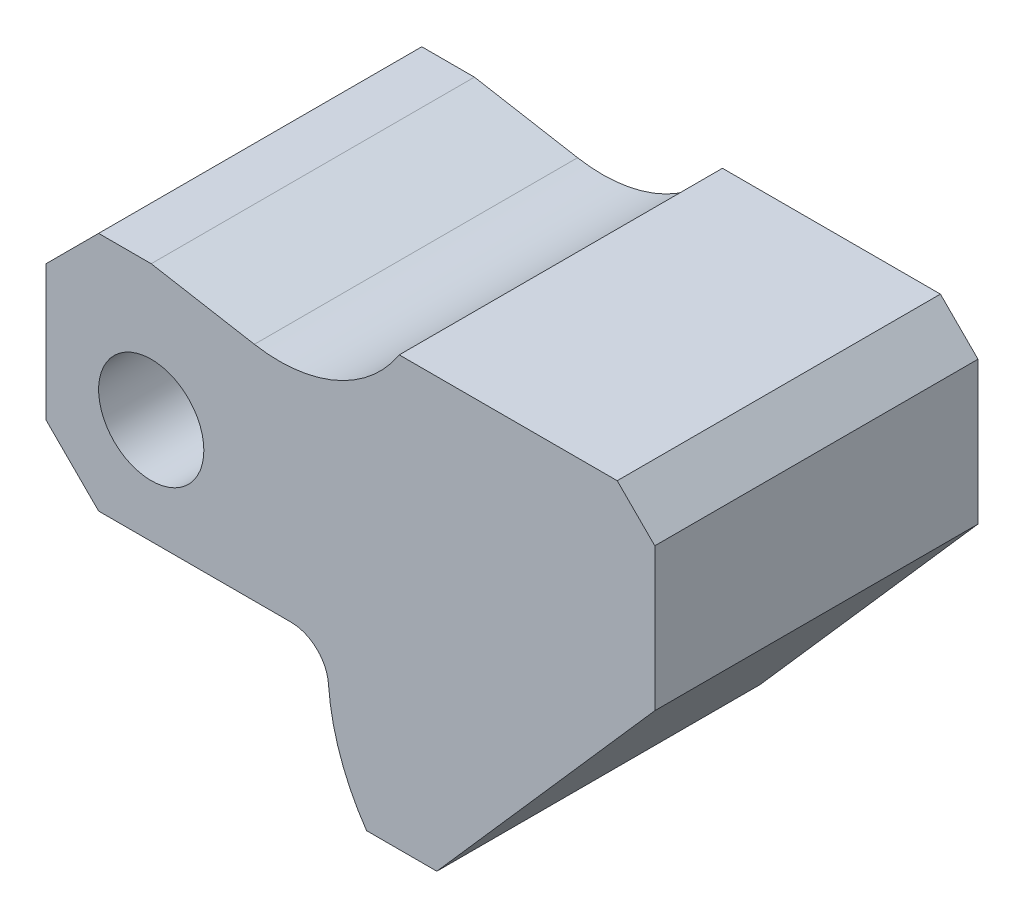
from build123d import *

# Parameters (mm, degrees)
SKETCH2_R           = 7
BOSS_EXTRUDE1_DEPTH = 43


with BuildPart() as part:
    # Sketch2 → Boss-Extrude1 (new body)
    with BuildSketch(Plane.XY):
        with BuildLine():
            Line((-14, 11), (-14, -7))
            Line((-14, -7), (-7, -14))
            Line((-7, -14), (18.592036334, -14))
            ThreePointArc((18.592036334, -14), (21.995105882, -15.336788616), (23.578501579, -18.632352941))
            ThreePointArc((23.578501579, -18.632352941), (25.154525473, -26.155310607), (28.651519965, -33))
            Line((28.651519965, -33), (38, -33))
            Line((38, -33), (67, 0))
            Line((67, 0), (67, 19))
            Line((67, 19), (62, 24))
            Line((62, 24), (33, 24))
            ThreePointArc((33, 24), (24.635682091, 16.880152192), (13.728724936, 15.579255383))
            Line((13.728724936, 15.579255383), (0, 18))
            Line((0, 18), (-7, 18))
            Line((-7, 18), (-14, 11))
        make_face()
        Circle(SKETCH2_R, mode=Mode.SUBTRACT)
    extrude(amount=BOSS_EXTRUDE1_DEPTH)


solid = part.part
